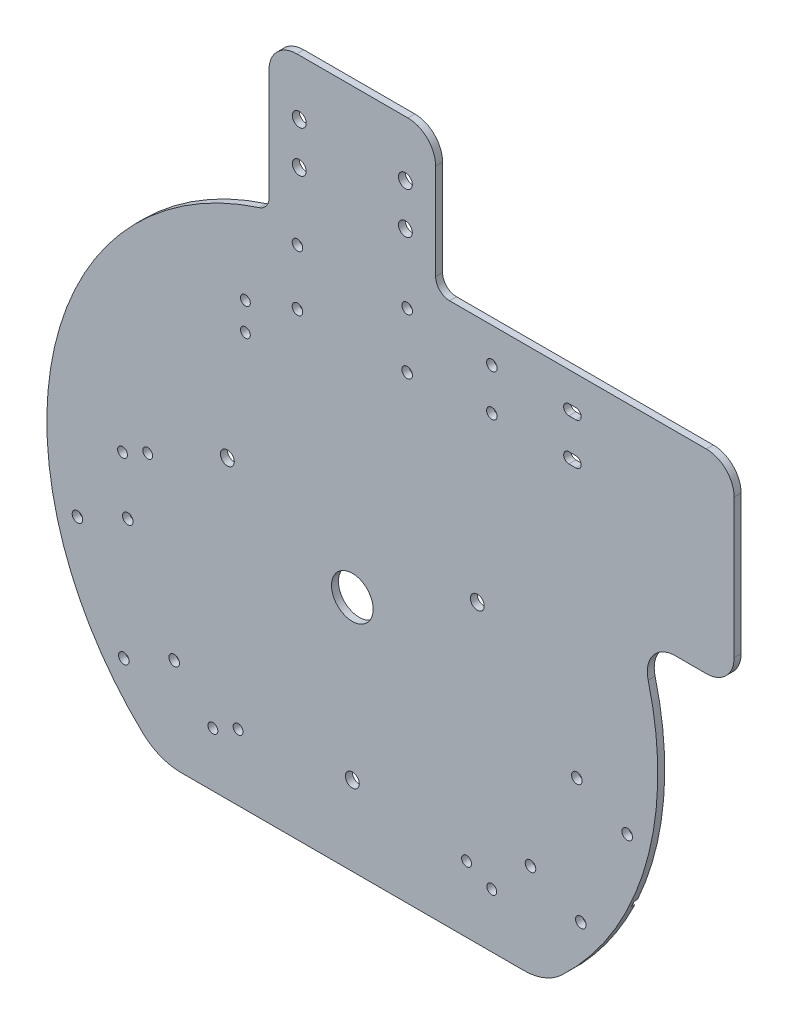
from build123d import *

# Parameters (mm, degrees)
BOSS_EXTRUDE1_DEPTH = 3.175
CUT_EXTRUDE3_DEPTH  = 1.5875
SKETCH3_R           = 9.525
CUT_EXTRUDE4_DEPTH  = 4.175
CUT_EXTRUDE5_DEPTH  = 4.175
SKETCH8_R           = 2.413
CUT_EXTRUDE7_DEPTH  = 4.175
SKETCH9_R           = 2.413
CUT_EXTRUDE8_DEPTH  = 4.175
FILLET1_R           = 12.7
CUT_EXTRUDE9_DEPTH  = 4.175
FILLET2_R           = 25.4
SKETCH11_R          = 2.2479
CUT_EXTRUDE10_DEPTH = 4.175
SKETCH14_R          = 3.175
BOSS_EXTRUDE2_DEPTH = 3.175
FILLET3_R           = 12.7
FILLET4_R           = 6.35


with BuildPart() as part:
    # Sketch1 → Boss-Extrude1 (new body)
    with BuildSketch(Plane.XY):
        with BuildLine():
            Line((0, 139.7), (139.7, 139.7))
            Line((139.7, 139.7), (174.625, 139.7))
            Line((174.625, 139.7), (174.625, 50.700684167))
            Line((174.625, 50.700684167), (130.175, 50.700684167))
            ThreePointArc((130.175, 50.700684167), (-78.845432404, -115.323405209), (0, 139.7))
        make_face()
    extrude(amount=BOSS_EXTRUDE1_DEPTH)

    # Sketch2 → Cut-Extrude3 (cut)
    with BuildSketch(Plane(origin=(0, 0, 0), x_dir=(-1, 0, 0), z_dir=(0, 0, -1))):
        Polygon((-1.5875, -1.011349039), (-1.5875, -2.491875854), (0, -1.751612446), align=None)
        Polygon((-1.5875, -1.011349039), (0, -1.751612446), (1.5875, -1.011349039), (1.5875, 1.011349039), (0, 1.751612446), (-1.5875, 1.011349039), align=None)
        Polygon((1.5875, -1.011349039), (0, -1.751612446), (1.5875, -2.491875854), align=None)
        Polygon((-3.756345013, 0), (-1.5875, -1.011349039), (-1.5875, 1.011349039), align=None)
        Polygon((-1.5875, 2.491875854), (-1.5875, 1.011349039), (0, 1.751612446), align=None)
        Polygon((0, 1.751612446), (1.5875, 1.011349039), (1.5875, 2.491875854), align=None)
        Polygon((1.5875, 1.011349039), (1.5875, -1.011349039), (3.756345013, 0), align=None)
        with BuildLine():
            ThreePointArc((-127.273929282, -57.597195461), (-126.611197849, -59.039771165), (-125.932116301, -60.474722685))
            Line((-125.932116301, -60.474722685), (-120.185236911, -57.794908815))
            Line((-120.185236911, -57.794908815), (-121.527049892, -54.917381591))
            Line((-121.527049892, -54.917381591), (-127.273929282, -57.597195461))
        make_face()
        with BuildLine():
            Line((121.527049892, 54.917381591), (127.273929282, 57.597195461))
            ThreePointArc((127.273929282, 57.597195461), (126.611197849, 59.039771165), (125.932116301, 60.474722685))
            Line((125.932116301, 60.474722685), (120.185236911, 57.794908815))
            Line((120.185236911, 57.794908815), (121.527049892, 54.917381591))
        make_face()
        with BuildLine():
            Line((120.185236911, -57.794908815), (125.932116301, -60.474722685))
            ThreePointArc((125.932116301, -60.474722685), (126.611197849, -59.039771165), (127.273929282, -57.597195461))
            Line((127.273929282, -57.597195461), (121.527049892, -54.917381591))
            Line((121.527049892, -54.917381591), (120.185236911, -57.794908815))
        make_face()
        with BuildLine():
            Line((0, 139.7), (-1.5875, 139.7))
            Line((-1.5875, 139.7), (-1.5875, 133.35))
            Line((-1.5875, 133.35), (1.5875, 133.35))
            Line((1.5875, 133.35), (1.5875, 139.690979822))
            ThreePointArc((1.5875, 139.690979822), (0.793762813, 139.697744937), (0, 139.7))
        make_face()
    extrude(amount=-CUT_EXTRUDE3_DEPTH, mode=Mode.SUBTRACT)

    # Sketch3 → Cut-Extrude4 (cut, through all)
    with BuildSketch(Plane.XY.offset(3.175)):
        Circle(SKETCH3_R)
    extrude(amount=-CUT_EXTRUDE4_DEPTH, mode=Mode.SUBTRACT)

    # Sketch2_4 → Cut-Extrude5 (cut, through all)
    with BuildSketch(Plane(origin=(0, 0, 0), x_dir=(-1, 0, 0), z_dir=(0, 0, -1))):
        with BuildLine():
            Line((-60.312918166, 26.37276318), (-55.328894815, 24.048674923))
            ThreePointArc((-55.328894815, 24.048674923), (-54.333740605, 25.183430817), (-53.975, 26.649482664))
            ThreePointArc((-53.975, 26.649482664), (-53.978021896, 26.787974218), (-53.987081834, 26.926202147))
            Line((-53.987081834, 26.926202147), (-58.971105185, 29.250290404))
            ThreePointArc((-58.971105185, 29.250290404), (-60.027527224, 27.991295645), (-60.312918166, 26.37276318))
        make_face()
        with BuildLine():
            ThreePointArc((-60.312918166, 26.37276318), (-58.491812981, 23.77195544), (-55.328894815, 24.048674923))
            Line((-55.328894815, 24.048674923), (-60.312918166, 26.37276318))
        make_face()
        with BuildLine():
            Line((-58.971105185, 29.250290404), (-53.987081834, 26.926202147))
            ThreePointArc((-53.987081834, 26.926202147), (-55.808187019, 29.527009887), (-58.971105185, 29.250290404))
        make_face()
        with BuildLine():
            ThreePointArc((53.987081834, 26.926202147), (54.272472776, 25.307669683), (55.328894815, 24.048674923))
            Line((55.328894815, 24.048674923), (60.312918166, 26.37276318))
            ThreePointArc((60.312918166, 26.37276318), (60.321978104, 26.510991109), (60.325, 26.649482664))
            ThreePointArc((60.325, 26.649482664), (59.966259395, 28.115534511), (58.971105185, 29.250290404))
            Line((58.971105185, 29.250290404), (53.987081834, 26.926202147))
        make_face()
        with BuildLine():
            ThreePointArc((58.971105185, 29.250290404), (55.808187019, 29.527009887), (53.987081834, 26.926202147))
            Line((53.987081834, 26.926202147), (58.971105185, 29.250290404))
        make_face()
        with BuildLine():
            Line((60.312918166, 26.37276318), (55.328894815, 24.048674923))
            ThreePointArc((55.328894815, 24.048674923), (58.491812981, 23.77195544), (60.312918166, 26.37276318))
        make_face()
        with BuildLine():
            ThreePointArc((-1.5875, -69.587590332), (-3.175, -72.337220989), (-1.5875, -75.086851646))
            Line((-1.5875, -75.086851646), (-1.5875, -69.587590332))
        make_face()
        with BuildLine():
            Line((-1.5875, -69.587590332), (-1.5875, -75.086851646))
            ThreePointArc((-1.5875, -75.086851646), (0, -75.512220989), (1.5875, -75.086851646))
            Line((1.5875, -75.086851646), (1.5875, -69.587590332))
            ThreePointArc((1.5875, -69.587590332), (0, -69.162220989), (-1.5875, -69.587590332))
        make_face()
        with BuildLine():
            Line((1.5875, -69.587590332), (1.5875, -75.086851646))
            ThreePointArc((1.5875, -75.086851646), (2.749630657, -73.924720989), (3.175, -72.337220989))
            ThreePointArc((3.175, -72.337220989), (2.749630657, -70.749720989), (1.5875, -69.587590332))
        make_face()
    extrude(amount=-CUT_EXTRUDE5_DEPTH, mode=Mode.SUBTRACT)

    # Sketch8 → Cut-Extrude7 (cut, through all)
    with BuildSketch(Plane.XY.offset(3.175)):
        with Locations((25.0825, 101.6)):
            Circle(SKETCH8_R)
        with Locations((-25.0825, 101.6)):
            Circle(SKETCH8_R)
        with Locations((-25.0825, 127)):
            Circle(SKETCH8_R)
        with Locations((25.0825, 127)):
            Circle(SKETCH8_R)
        with Locations((102.681193713, -20.205550325)):
            Circle(SKETCH8_R)
        with Locations((125.701411504, -30.940054173)):
            Circle(SKETCH8_R)
        with Locations((81.480548613, -65.670480461)):
            Circle(SKETCH8_R)
        with Locations((104.500766404, -76.404984309)):
            Circle(SKETCH8_R)
        with Locations((-81.480548613, -65.670480461)):
            Circle(SKETCH8_R)
        with Locations((-104.500766404, -76.404984309)):
            Circle(SKETCH8_R)
        with Locations((-102.681193713, -20.205550325)):
            Circle(SKETCH8_R)
        with Locations((-125.701411504, -30.940054173)):
            Circle(SKETCH8_R)
    extrude(amount=-CUT_EXTRUDE7_DEPTH, mode=Mode.SUBTRACT)

    # Sketch9 → Cut-Extrude8 (cut, through all)
    with BuildSketch(Plane.XY.offset(3.175)):
        with Locations((100.6475, 123.825)):
            Circle(SKETCH9_R)
        with Locations((63.8175, 123.825)):
            Circle(SKETCH9_R)
        with Locations((63.8175, 104.775)):
            Circle(SKETCH9_R)
        with Locations((100.6475, 104.775)):
            Circle(SKETCH9_R)
        with BuildLine():
            Line((99.06, 121.412), (100.6475, 121.412))
            ThreePointArc((100.6475, 121.412), (98.2345, 123.825000011), (100.647500021, 126.238))
            Line((100.647500021, 126.238), (99.06, 126.238))
            ThreePointArc((99.06, 126.238), (96.647, 123.825), (99.06, 121.412))
        make_face()
        with BuildLine():
            Line((100.6475, 121.412), (102.235, 121.412))
            ThreePointArc((102.235, 121.412), (104.648, 123.825), (102.235, 126.238))
            Line((102.235, 126.238), (100.647500021, 126.238))
            ThreePointArc((100.647500021, 126.238), (102.353748671, 125.531248656), (103.0605, 123.825))
            ThreePointArc((103.0605, 123.825), (102.353748663, 122.118751337), (100.6475, 121.412))
        make_face()
        with BuildLine():
            ThreePointArc((100.647500034, 102.362), (98.2345, 104.774999983), (100.6475, 107.188))
            Line((100.6475, 107.188), (99.06, 107.188))
            ThreePointArc((99.06, 107.188), (96.647, 104.775), (99.06, 102.362))
            Line((99.06, 102.362), (100.647500034, 102.362))
        make_face()
        with BuildLine():
            ThreePointArc((102.235, 102.362), (104.648, 104.775), (102.235, 107.188))
            Line((102.235, 107.188), (100.6475, 107.188))
            ThreePointArc((100.6475, 107.188), (102.353748663, 106.481248663), (103.0605, 104.775))
            ThreePointArc((103.0605, 104.775), (102.353748675, 103.068751349), (100.647500034, 102.362))
            Line((100.647500034, 102.362), (102.235, 102.362))
        make_face()
    extrude(amount=-CUT_EXTRUDE8_DEPTH, mode=Mode.SUBTRACT)

    # Fillet1
    fillet1_edges = [part.edges().sort_by_distance(p)[0] for p in [
        (174.625, 139.7, 1.5875),
        (174.625, 50.700684167, 1.5875),
        (130.175, 50.700684167, 1.5875),
    ]]
    fillet(fillet1_edges, radius=FILLET1_R)

    # Sketch10 → Cut-Extrude9 (cut, through all)
    with BuildSketch(Plane.XY.offset(3.175)):
        with BuildLine():
            Line((87.894185103, -108.585), (-87.894185103, -108.585))
            ThreePointArc((-87.894185103, -108.585), (0, -139.7), (87.894185103, -108.585))
        make_face()
    extrude(amount=-CUT_EXTRUDE9_DEPTH, mode=Mode.SUBTRACT)

    # Fillet2
    fillet2_edges = [part.edges().sort_by_distance(p)[0] for p in [
        (-87.894185103, -108.585, 1.5875),
        (87.894185103, -108.585, 1.5875),
    ]]
    fillet(fillet2_edges, radius=FILLET2_R)

    # Sketch11 → Cut-Extrude10 (cut, through all)
    with BuildSketch(Plane.XY.offset(3.175)):
        with Locations((-93.58045976, 10.312378308)):
            Circle(SKETCH11_R)
        with Locations((-105.090568655, 4.945126384)):
            Circle(SKETCH11_R)
        with Locations((-52.252619944, -78.315460186)):
            Circle(SKETCH11_R)
        with Locations((-63.762728839, -83.682712111)):
            Circle(SKETCH11_R)
        with Locations((52.252619944, -78.315460186)):
            Circle(SKETCH11_R)
        with Locations((63.76272884, -83.68271211)):
            Circle(SKETCH11_R)
        with Locations((-48.895, 93.1545)):
            Circle(SKETCH11_R)
        with Locations((-48.895, 80.4545)):
            Circle(SKETCH11_R)
    extrude(amount=-CUT_EXTRUDE10_DEPTH, mode=Mode.SUBTRACT)

    # Sketch14 → Boss-Extrude2 (add)
    with BuildSketch(Plane(origin=(0, 0, 0), x_dir=(-1, 0, 0), z_dir=(0, 0, -1))):
        with BuildLine():
            Line((-38.1, 139.7), (-38.1, 202.565))
            Line((-38.1, 202.565), (38.1, 202.565))
            Line((38.1, 202.565), (38.1, 134.404166602))
            ThreePointArc((38.1, 134.404166602), (19.233147502, 138.369707802), (0, 139.7))
            Line((0, 139.7), (-38.1, 139.7))
        make_face()
        with Locations((-24.257, 177.165)):
            Circle(SKETCH14_R, mode=Mode.SUBTRACT)
        with Locations((24.257, 177.165)):
            Circle(SKETCH14_R, mode=Mode.SUBTRACT)
        with Locations((24.257, 158.115)):
            Circle(SKETCH14_R, mode=Mode.SUBTRACT)
        with Locations((-24.257, 158.115)):
            Circle(SKETCH14_R, mode=Mode.SUBTRACT)
    extrude(amount=-BOSS_EXTRUDE2_DEPTH)

    # Fillet3
    fillet3_edges = [part.edges().sort_by_distance(p)[0] for p in [
        (38.1, 202.565, 1.5875),
        (-38.1, 202.565, 1.5875),
    ]]
    fillet(fillet3_edges, radius=FILLET3_R)

    # Fillet4
    fillet4_edges = [part.edges().sort_by_distance(p)[0] for p in [
        (-38.1, 134.404166602, 1.5875),
        (38.1, 139.7, 1.5875),
    ]]
    fillet(fillet4_edges, radius=FILLET4_R)


solid = part.part
